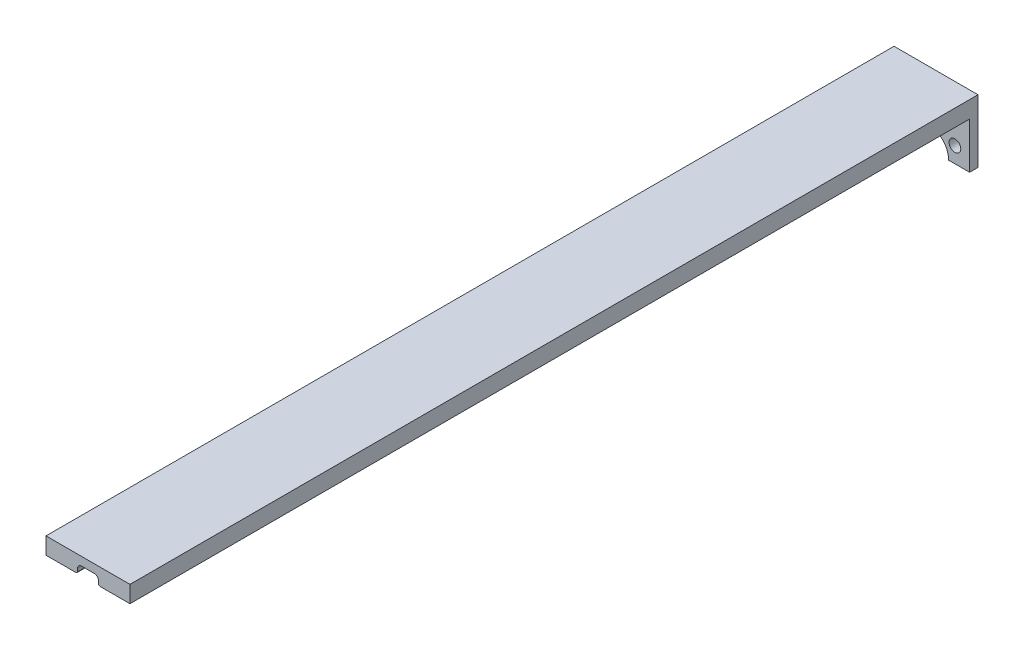
from build123d import *

# Parameters (mm, degrees)
SKETCH2_R           = 1.778
BOSS_EXTRUDE1_DEPTH = 2.54
BOSS_EXTRUDE2_DEPTH = 254


with BuildPart() as part:
    # Sketch2 → Boss-Extrude1 (new body)
    with BuildSketch(Plane.XY):
        with BuildLine():
            Line((-12.7, 0), (-6.35, 0))
            ThreePointArc((-6.35, 0), (0, 6.35), (6.35, 0))
            Line((6.35, 0), (12.7, 0))
            Line((12.7, 0), (12.7, 19.05))
            Line((12.7, 19.05), (-12.7, 19.05))
            Line((-12.7, 19.05), (-12.7, 0))
        make_face()
        with Locations((-8.248891971, 4.7625)):
            Circle(SKETCH2_R, mode=Mode.SUBTRACT)
        with Locations((8.248891971, 4.7625)):
            Circle(SKETCH2_R, mode=Mode.SUBTRACT)
    extrude(amount=BOSS_EXTRUDE1_DEPTH)

    # Sketch3 → Boss-Extrude2 (add)
    with BuildSketch(Plane.XY.offset(2.54)):
        with BuildLine():
            Line((-12.7, 19.05), (-12.7, 13.97))
            Line((-12.7, 13.97), (-3.683, 13.97))
            ThreePointArc((-3.683, 13.97), (-3.323789755, 14.118789755), (-3.175, 14.478))
            Line((-3.175, 14.478), (-3.175, 15.24))
            ThreePointArc((-3.175, 15.24), (-2.803025612, 16.138025612), (-1.905, 16.51))
            Line((-1.905, 16.51), (1.905, 16.51))
            ThreePointArc((1.905, 16.51), (2.803025612, 16.138025612), (3.175, 15.24))
            Line((3.175, 15.24), (3.175, 14.478))
            ThreePointArc((3.175, 14.478), (3.323789755, 14.118789755), (3.683, 13.97))
            Line((3.683, 13.97), (12.7, 13.97))
            Line((12.7, 13.97), (12.7, 19.05))
            Line((12.7, 19.05), (-12.7, 19.05))
        make_face()
    extrude(amount=BOSS_EXTRUDE2_DEPTH)


solid = part.part
